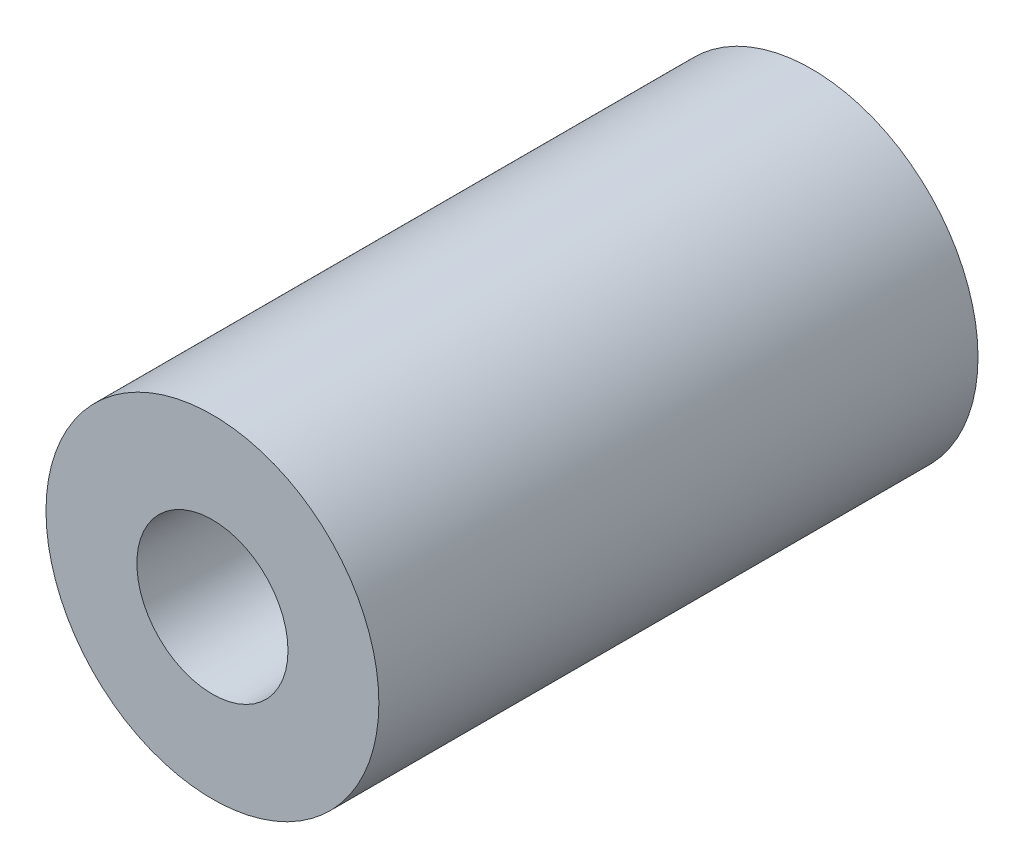
from build123d import *

# Parameters (mm, degrees)
SKETCH1_R           = 5
BOSS_EXTRUDE1_DEPTH = 18
SKETCH2_R           = 2.27
CUT_EXTRUDE1_DEPTH  = 5.68
CUT_EXTRUDE1_TAPER  = 3.074
SKETCH7_R           = 1
CUT_EXTRUDE2_DEPTH  = 19
SKETCH9_R           = 2.27
CUT_EXTRUDE3_DEPTH  = 5.68
CUT_EXTRUDE3_TAPER  = 3.074


with BuildPart() as part:
    # Sketch1 → Boss-Extrude1 (new body)
    with BuildSketch(Plane.XY):
        Circle(SKETCH1_R)
    extrude(amount=BOSS_EXTRUDE1_DEPTH)

    # Sketch2 → Cut-Extrude1 (cut)
    with BuildSketch(Plane.XY):
        Circle(SKETCH2_R)
    extrude(amount=CUT_EXTRUDE1_DEPTH, taper=CUT_EXTRUDE1_TAPER, mode=Mode.SUBTRACT)

    # Sketch7 → Cut-Extrude2 (cut, through all)
    with BuildSketch(Plane.XY):
        Circle(SKETCH7_R)
    extrude(amount=CUT_EXTRUDE2_DEPTH, mode=Mode.SUBTRACT)

    # Sketch9 → Cut-Extrude3 (cut)
    with BuildSketch(Plane.XY.offset(18)):
        Circle(SKETCH9_R)
    extrude(amount=-CUT_EXTRUDE3_DEPTH, taper=CUT_EXTRUDE3_TAPER, mode=Mode.SUBTRACT)


solid = part.part
